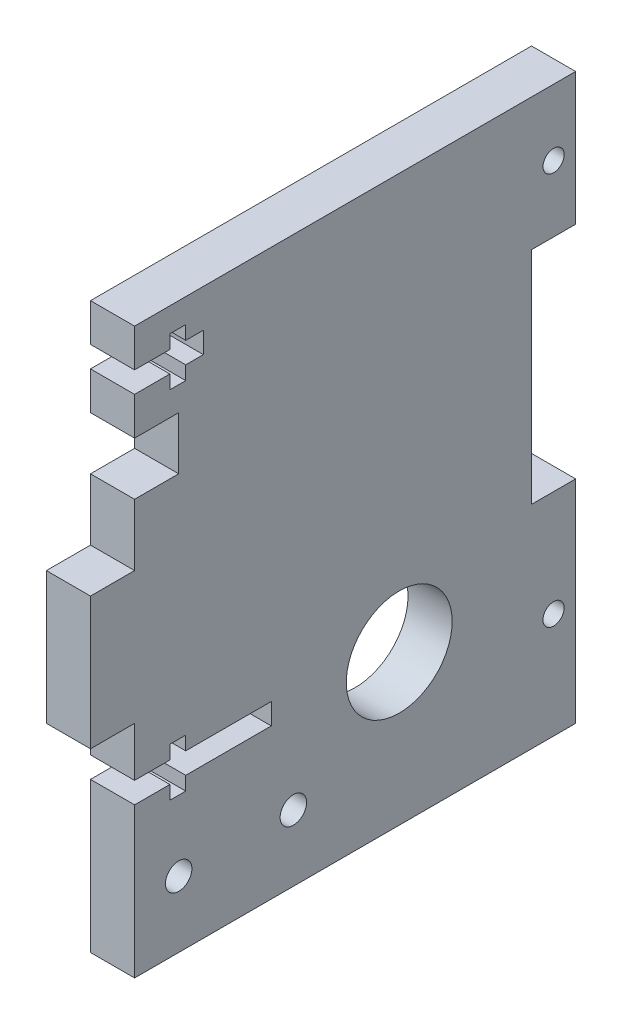
from build123d import *

# Parameters (mm, degrees)
SKETCH1_R           = 6
SKETCH1_R_2         = 1.5
SKETCH1_W           = 8
SKETCH1_H           = 2.4
BOSS_EXTRUDE1_DEPTH = 5
SKETCH2_R           = 1.2
CUT_EXTRUDE1_DEPTH  = 6


with BuildPart() as part:
    # Sketch1 → Boss-Extrude1 (new body)
    with BuildSketch(Plane(origin=(0, 0, 0), x_dir=(0, 0, -1), z_dir=(1, 0, 0))):
        Polygon((0, 0), (-50, 0), (-50, 25), (-55, 25), (-55, 40), (-50, 40), (-50, 47), (-45, 47), (-45, 53), (-50, 53), (-50, 64), (0, 64), (0, 49), (-5, 49), (-5, 24), (0, 24), align=None)
        with Locations((-20, 17)):
            Circle(SKETCH1_R, mode=Mode.SUBTRACT)
        with Locations((-45, 7.5)):
            Circle(SKETCH1_R_2, mode=Mode.SUBTRACT)
        with Locations((-32, 7.5)):
            Circle(SKETCH1_R_2, mode=Mode.SUBTRACT)
        with Locations((-38.5, 18.2)):
            Rectangle(SKETCH1_W, SKETCH1_H, mode=Mode.SUBTRACT)
    extrude(amount=BOSS_EXTRUDE1_DEPTH)

    # Sketch2 → Cut-Extrude1 (cut, through all)
    with BuildSketch(Plane(origin=(5, 0, 0), x_dir=(0, 0, -1), z_dir=(1, 0, 0))):
        with Locations((-2.5, 56.5)):
            Circle(SKETCH2_R)
        with Locations((-2.5, 12)):
            Circle(SKETCH2_R)
        Polygon((-50, 59.7), (-46, 59.7), (-46, 61.25), (-44.2, 61.25), (-44.2, 59.7), (-42.2, 59.7), (-42.2, 57.3), (-44.2, 57.3), (-44.2, 55.75), (-46, 55.75), (-46, 57.3), (-50, 57.3), align=None)
        Polygon((-44.2, 19.4), (-42.2, 19.4), (-42.2, 17), (-44.2, 17), (-44.2, 15.45), (-46, 15.45), (-46, 17), (-50, 17), (-50, 19.4), (-46, 19.4), (-46, 20.95), (-44.2, 20.95), align=None)
    extrude(amount=-CUT_EXTRUDE1_DEPTH, mode=Mode.SUBTRACT)


solid = part.part
